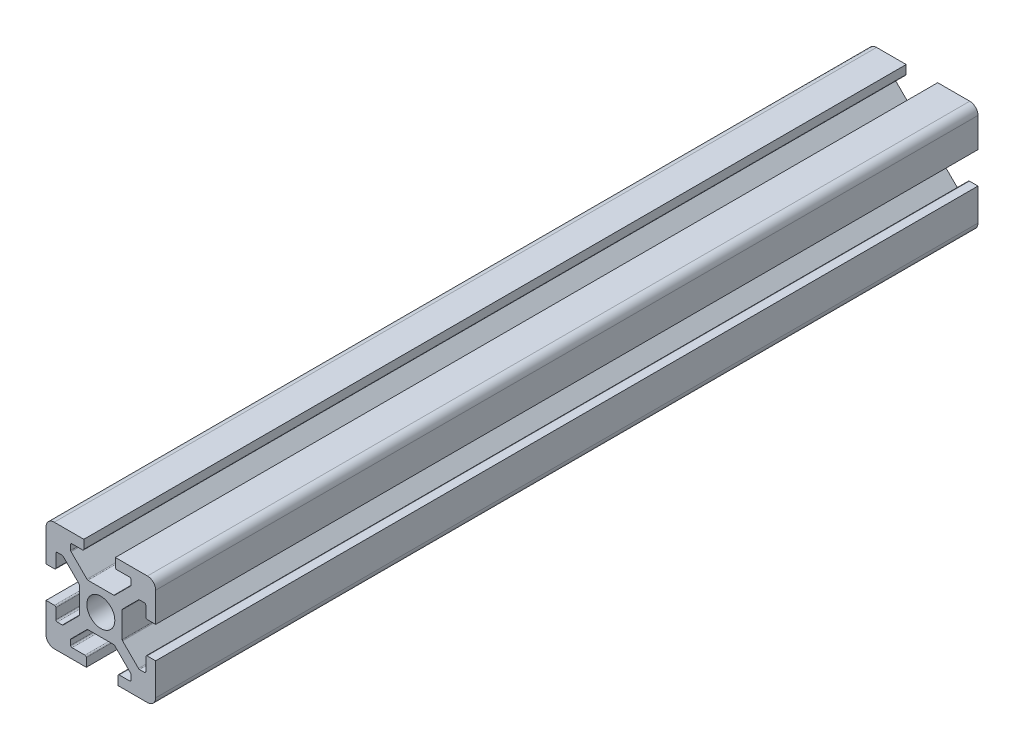
from build123d import *

# Parameters (mm, degrees)
SKETCH1_R           = 2.55
BOSS_EXTRUDE1_DEPTH = 150


with BuildPart() as part:
    # Sketch1 → Boss-Extrude1 (new body)
    with BuildSketch(Plane.XY):
        with BuildLine():
            Line((-8.5, -10), (-2.647623804, -10))
            Line((-2.647623804, -10), (-2.647623804, -8.45))
            ThreePointArc((-2.647623804, -8.45), (-2.720847109, -8.273223305), (-2.897623804, -8.2))
            Line((-2.897623804, -8.2), (-5.25, -8.2))
            ThreePointArc((-5.25, -8.2), (-5.426776695, -8.126776695), (-5.5, -7.95))
            Line((-5.5, -7.95), (-5.5, -7.053553391))
            ThreePointArc((-5.5, -7.053553391), (-5.480969883, -6.957882533), (-5.426776695, -6.876776695))
            Line((-5.426776695, -6.876776695), (-2.523223305, -3.973223305))
            ThreePointArc((-2.523223305, -3.973223305), (-2.442117467, -3.919030117), (-2.346446609, -3.9))
            Line((-2.346446609, -3.9), (2.346446609, -3.9))
            ThreePointArc((2.346446609, -3.9), (2.442117467, -3.919030117), (2.523223305, -3.973223305))
            Line((2.523223305, -3.973223305), (5.426776695, -6.876776695))
            ThreePointArc((5.426776695, -6.876776695), (5.480969883, -6.957882533), (5.5, -7.053553391))
            Line((5.5, -7.053553391), (5.5, -7.95))
            ThreePointArc((5.5, -7.95), (5.426776695, -8.126776695), (5.25, -8.2))
            Line((5.25, -8.2), (3.35, -8.2))
            ThreePointArc((3.35, -8.2), (3.173223305, -8.273223305), (3.1, -8.45))
            Line((3.1, -8.45), (3.1, -10))
            Line((3.1, -10), (8.5, -10))
            ThreePointArc((8.5, -10), (9.560660172, -9.560660172), (10, -8.5))
            Line((10, -8.5), (10, -2.647623804))
            Line((10, -2.647623804), (8.45, -2.647623804))
            ThreePointArc((8.45, -2.647623804), (8.273223305, -2.720847109), (8.2, -2.897623804))
            Line((8.2, -2.897623804), (8.2, -5.25))
            ThreePointArc((8.2, -5.25), (8.126776695, -5.426776695), (7.95, -5.5))
            Line((7.95, -5.5), (7.053553391, -5.5))
            ThreePointArc((7.053553391, -5.5), (6.957882533, -5.480969883), (6.876776695, -5.426776695))
            Line((6.876776695, -5.426776695), (3.973223305, -2.523223305))
            ThreePointArc((3.973223305, -2.523223305), (3.919030117, -2.442117467), (3.9, -2.346446609))
            Line((3.9, -2.346446609), (3.9, 2.346446609))
            ThreePointArc((3.9, 2.346446609), (3.919030117, 2.442117467), (3.973223305, 2.523223305))
            Line((3.973223305, 2.523223305), (6.876776695, 5.426776695))
            ThreePointArc((6.876776695, 5.426776695), (6.957882533, 5.480969883), (7.053553391, 5.5))
            Line((7.053553391, 5.5), (7.95, 5.5))
            ThreePointArc((7.95, 5.5), (8.126776695, 5.426776695), (8.2, 5.25))
            Line((8.2, 5.25), (8.2, 3.35))
            ThreePointArc((8.2, 3.35), (8.273223305, 3.173223305), (8.45, 3.1))
            Line((8.45, 3.1), (10, 3.1))
            Line((10, 3.1), (10, 8.5))
            ThreePointArc((10, 8.5), (9.560660172, 9.560660172), (8.5, 10))
            Line((8.5, 10), (2.647623804, 10))
            Line((2.647623804, 10), (2.647623804, 8.45))
            ThreePointArc((2.647623804, 8.45), (2.720847109, 8.273223305), (2.897623804, 8.2))
            Line((2.897623804, 8.2), (5.25, 8.2))
            ThreePointArc((5.25, 8.2), (5.426776695, 8.126776695), (5.5, 7.95))
            Line((5.5, 7.95), (5.5, 7.053553391))
            ThreePointArc((5.5, 7.053553391), (5.480969883, 6.957882533), (5.426776695, 6.876776695))
            Line((5.426776695, 6.876776695), (2.523223305, 3.973223305))
            ThreePointArc((2.523223305, 3.973223305), (2.442117467, 3.919030117), (2.346446609, 3.9))
            Line((2.346446609, 3.9), (-2.346446609, 3.9))
            ThreePointArc((-2.346446609, 3.9), (-2.442117467, 3.919030117), (-2.523223305, 3.973223305))
            Line((-2.523223305, 3.973223305), (-5.426776695, 6.876776695))
            ThreePointArc((-5.426776695, 6.876776695), (-5.480969883, 6.957882533), (-5.5, 7.053553391))
            Line((-5.5, 7.053553391), (-5.5, 7.95))
            ThreePointArc((-5.5, 7.95), (-5.426776695, 8.126776695), (-5.25, 8.2))
            Line((-5.25, 8.2), (-3.35, 8.2))
            ThreePointArc((-3.35, 8.2), (-3.173223305, 8.273223305), (-3.1, 8.45))
            Line((-3.1, 8.45), (-3.1, 10))
            Line((-3.1, 10), (-8.5, 10))
            ThreePointArc((-8.5, 10), (-9.560660172, 9.560660172), (-10, 8.5))
            Line((-10, 8.5), (-10, 2.647623804))
            Line((-10, 2.647623804), (-8.45, 2.647623804))
            ThreePointArc((-8.45, 2.647623804), (-8.273223305, 2.720847109), (-8.2, 2.897623804))
            Line((-8.2, 2.897623804), (-8.2, 5.25))
            ThreePointArc((-8.2, 5.25), (-8.126776695, 5.426776695), (-7.95, 5.5))
            Line((-7.95, 5.5), (-7.053553391, 5.5))
            ThreePointArc((-7.053553391, 5.5), (-6.957882533, 5.480969883), (-6.876776695, 5.426776695))
            Line((-6.876776695, 5.426776695), (-3.973223305, 2.523223305))
            ThreePointArc((-3.973223305, 2.523223305), (-3.919030117, 2.442117467), (-3.9, 2.346446609))
            Line((-3.9, 2.346446609), (-3.9, -2.346446609))
            ThreePointArc((-3.9, -2.346446609), (-3.919030117, -2.442117467), (-3.973223305, -2.523223305))
            Line((-3.973223305, -2.523223305), (-6.876776695, -5.426776695))
            ThreePointArc((-6.876776695, -5.426776695), (-6.957882533, -5.480969883), (-7.053553391, -5.5))
            Line((-7.053553391, -5.5), (-7.95, -5.5))
            ThreePointArc((-7.95, -5.5), (-8.126776695, -5.426776695), (-8.2, -5.25))
            Line((-8.2, -5.25), (-8.2, -3.35))
            ThreePointArc((-8.2, -3.35), (-8.273223305, -3.173223305), (-8.45, -3.1))
            Line((-8.45, -3.1), (-10, -3.1))
            Line((-10, -3.1), (-10, -8.5))
            ThreePointArc((-10, -8.5), (-9.560660172, -9.560660172), (-8.5, -10))
        make_face()
        Circle(SKETCH1_R, mode=Mode.SUBTRACT)
    extrude(amount=BOSS_EXTRUDE1_DEPTH)


solid = part.part
